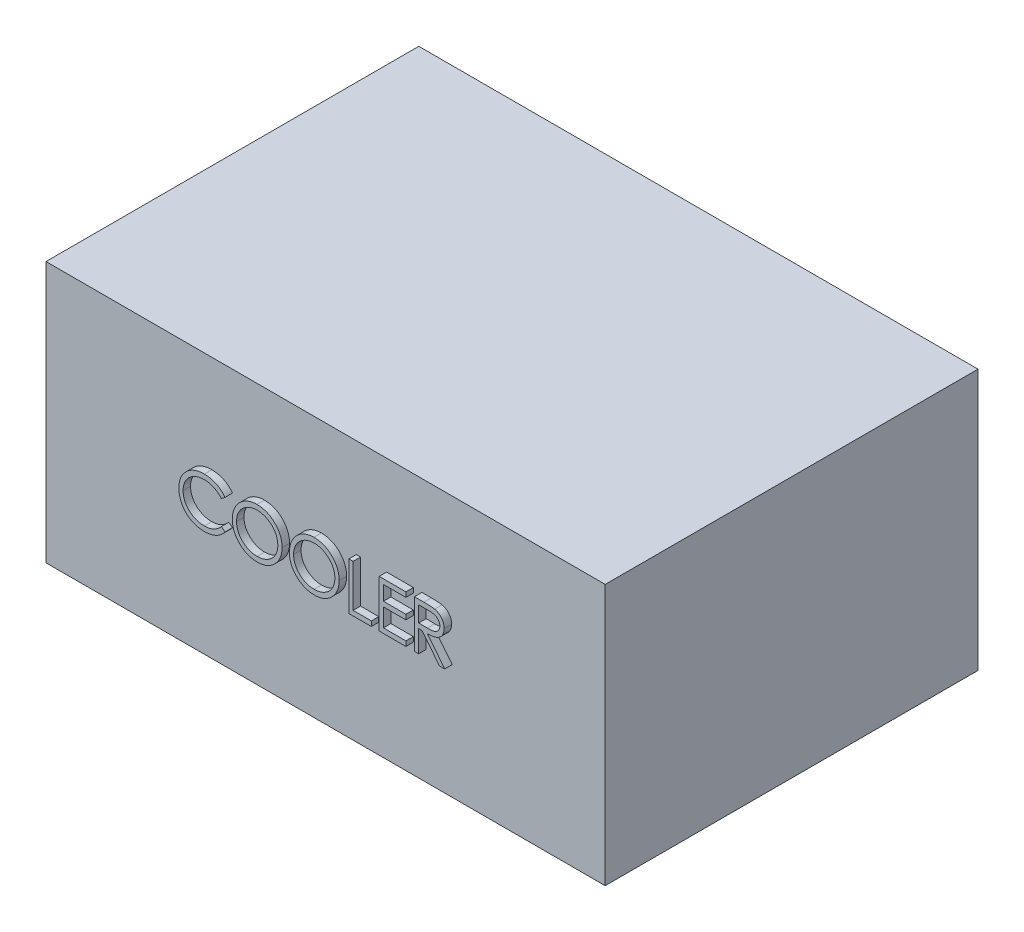
from build123d import *

# Parameters (mm, degrees)
SKETCH_1_W      = 150
SKETCH_1_H      = 70
EXTRUDE_1_DEPTH = 100
EXTRUDE_2_DEPTH = 2


with BuildPart() as part:
    # 스케치1 → 보스-돌출1 (new body)
    with BuildSketch(Plane.XY):
        with Locations((75, -35)):
            Rectangle(SKETCH_1_W, SKETCH_1_H)
    extrude(amount=EXTRUDE_1_DEPTH)

    # 스케치2 → 보스-돌출2 (add)
    with BuildSketch(Plane.XY.offset(100)):
        with BuildLine():
            Line((50.01625777, -28.786189706), (49.018982129, -29.54941086))
            add(Edge.make_bspline(
                [(49.018982129, -29.54941086), (48.947840763, -29.46462577), (48.80651717, -29.296198676), (48.579153778, -29.059690043), (48.342202102, -28.83811038), (48.095752719, -28.630404131), (47.835369629, -28.443834724), (47.567360445, -28.268679579), (47.287241824, -28.111679501), (46.89988553, -27.921313809), (46.393163337, -27.722663475), (45.755279207, -27.556100321), (45.089396078, -27.450069198), (44.635107645, -27.438585345), (44.404038219, -27.432744194)],
                knots=[0, 0, 0, 0, 0.00033196, 0.000659444, 0.000983431, 0.001304932, 0.001625525, 0.001943778, 0.002265016, 0.002588143, 0.003238217, 0.003893566, 0.004562806, 0.005255583, 0.005255583, 0.005255583, 0.005255583], degree=3))
            add(Edge.make_bspline(
                [(44.404038219, -27.432744194), (44.276735961, -27.43421), (44.023312931, -27.43712801), (43.647217041, -27.475623979), (43.27814397, -27.529730369), (42.916333793, -27.610013685), (42.562247057, -27.711514331), (42.213568913, -27.832800833), (41.875347593, -27.982859824), (41.542904272, -28.14871551), (41.224391135, -28.336049381), (40.923019962, -28.5403864), (40.639889906, -28.759439979), (40.374777, -28.994031136), (40.127410216, -29.243103393), (39.899581974, -29.509311147), (39.692080628, -29.791803319), (39.500793137, -30.086854827), (39.329478361, -30.393606242), (39.186041371, -30.713192926), (39.059022784, -31.0401421), (38.958514104, -31.378147741), (38.878959428, -31.724831491), (38.824067622, -32.081123779), (38.786009455, -32.446280273), (38.783105956, -32.693782636), (38.781642385, -32.818541469)],
                knots=[0, 0, 0, 0, 0.000381746, 0.00075995, 0.001133062, 0.001500343, 0.001870765, 0.002237676, 0.002606812, 0.002979993, 0.003351741, 0.00371443, 0.004071661, 0.004424911, 0.004775707, 0.005123948, 0.005475039, 0.005826461, 0.006178335, 0.006527846, 0.006876532, 0.007229865, 0.007584733, 0.007942761, 0.008310834, 0.008684951, 0.008684951, 0.008684951, 0.008684951], degree=3))
            add(Edge.make_bspline(
                [(38.781642385, -32.818541469), (38.786220986, -33.006252259), (38.79521046, -33.374797495), (38.875214416, -33.914622282), (38.996790032, -34.431768727), (39.17900084, -34.923004155), (39.403678538, -35.394385911), (39.687580185, -35.837938322), (40.016388764, -36.260364142), (40.394755943, -36.651679981), (40.809885618, -37.00914407), (41.255285183, -37.323924751), (41.729845313, -37.586324468), (42.228326228, -37.804677188), (42.754563842, -37.972523028), (43.307611839, -38.090684276), (43.886267365, -38.167763046), (44.281670616, -38.175142428), (44.482904405, -38.17889804)],
                knots=[0, 0, 0, 0, 0.000562815, 0.001105012, 0.001633818, 0.00215373, 0.002673724, 0.003197432, 0.003730267, 0.004277248, 0.00482748, 0.005371661, 0.005910344, 0.006451519, 0.007001839, 0.007564217, 0.008146414, 0.008749794, 0.008749794, 0.008749794, 0.008749794], degree=3))
            add(Edge.make_bspline(
                [(44.482904405, -38.17889804), (44.704619876, -38.172770182), (45.141008963, -38.160709092), (45.780972944, -38.058531245), (46.393605579, -37.892858229), (46.978939822, -37.661000053), (47.535325538, -37.359591723), (48.06363342, -36.994202282), (48.564309404, -36.561356046), (48.865376628, -36.230854409), (49.018982129, -36.062231373)],
                knots=[0, 0, 0, 0, 0.000664826, 0.001308536, 0.001938654, 0.00256556, 0.003192755, 0.00383282, 0.004489298, 0.005173128, 0.005173128, 0.005173128, 0.005173128], degree=3))
            Line((49.018982129, -36.062231373), (50.01625777, -36.817820315))
            add(Edge.make_bspline(
                [(50.01625777, -36.817820315), (49.936000628, -36.921374127), (49.775870772, -37.127985732), (49.516580254, -37.419257365), (49.243431203, -37.693229151), (48.95439477, -37.947692233), (48.652795926, -38.187738437), (48.33321925, -38.406547939), (47.999865903, -38.607174862), (47.653865365, -38.790878274), (47.295585256, -38.953863713), (46.925454878, -39.093395956), (46.545069647, -39.213591984), (46.154412173, -39.312477583), (45.752672141, -39.38966123), (45.341299278, -39.441258336), (44.919405731, -39.476607569), (44.634775432, -39.479829435), (44.490536616, -39.481462142)],
                knots=[0, 0, 0, 0, 0.00039295, 0.000784017, 0.001168988, 0.001552873, 0.001938676, 0.002324679, 0.002713864, 0.003105353, 0.00349929, 0.003893826, 0.004291304, 0.004695459, 0.005102104, 0.005517692, 0.005938765, 0.006371376, 0.006371376, 0.006371376, 0.006371376], degree=3))
            add(Edge.make_bspline(
                [(44.490536616, -39.481462142), (44.353943881, -39.480511484), (44.083848663, -39.478631674), (43.685073193, -39.448180095), (43.296853857, -39.406633907), (42.920300214, -39.34407686), (42.553357391, -39.270255969), (42.199351841, -39.171300266), (41.854800078, -39.060450433), (41.521086384, -38.930166624), (41.197926902, -38.783150762), (40.88636393, -38.616992819), (40.586540761, -38.433090053), (40.295509662, -38.235496158), (40.017569859, -38.017864234), (39.750312781, -37.783216732), (39.492239796, -37.532344522), (39.33257291, -37.351442625), (39.25229543, -37.260488585)],
                knots=[0, 0, 0, 0, 0.000409666, 0.000810065, 0.001199174, 0.001580615, 0.001954827, 0.00232143, 0.002682661, 0.003040299, 0.003395496, 0.003747176, 0.004098847, 0.004450261, 0.004801913, 0.005157073, 0.005516877, 0.005880706, 0.005880706, 0.005880706, 0.005880706], degree=3))
            add(Edge.make_bspline(
                [(39.25229543, -37.260488585), (39.123714667, -37.102496271), (38.868105479, -36.788419064), (38.541077999, -36.279381361), (38.261142584, -35.747911003), (38.0348071, -35.191215833), (37.85786804, -34.610545028), (37.735290561, -34.005605875), (37.655637596, -33.376963342), (37.646528834, -32.949384138), (37.641898796, -32.732043072)],
                knots=[0, 0, 0, 0, 0.000610709, 0.001214046, 0.001811469, 0.002410515, 0.003014109, 0.003629806, 0.004260284, 0.004912063, 0.004912063, 0.004912063, 0.004912063], degree=3))
            add(Edge.make_bspline(
                [(37.641898796, -32.732043072), (37.647541926, -32.503604712), (37.658644434, -32.0541665), (37.752972035, -31.394586727), (37.904714524, -30.762665936), (38.120240377, -30.159583777), (38.393491223, -29.582168189), (38.731044936, -29.034830103), (39.128979995, -28.514069144), (39.584175455, -28.027787047), (40.083348357, -27.583144253), (40.617905196, -27.191961742), (41.18679969, -26.866415327), (41.783764466, -26.594286395), (42.413269653, -26.385119343), (43.073972164, -26.238694923), (43.764630512, -26.147555672), (44.235845599, -26.136034203), (44.475272193, -26.130180091)],
                knots=[0, 0, 0, 0, 0.000685036, 0.001347765, 0.001994424, 0.002631723, 0.003265569, 0.003907406, 0.004557186, 0.005228594, 0.005902557, 0.006560016, 0.007211953, 0.007865497, 0.008525192, 0.009197944, 0.009893113, 0.01061119, 0.01061119, 0.01061119, 0.01061119], degree=3))
            add(Edge.make_bspline(
                [(44.475272193, -26.130180091), (44.621193277, -26.131929564), (44.910029367, -26.135392469), (45.337303277, -26.169160471), (45.753291149, -26.225452699), (46.15827957, -26.302073867), (46.554238777, -26.397169005), (46.938142508, -26.521049516), (47.312243458, -26.662696358), (47.674182239, -26.825831363), (48.022222292, -27.008953539), (48.35625522, -27.210033087), (48.673627707, -27.428820724), (48.976572957, -27.663455675), (49.260023208, -27.918901876), (49.532026288, -28.188133153), (49.783345057, -28.478904457), (49.938478079, -28.683573789), (50.01625777, -28.786189706)],
                knots=[0, 0, 0, 0, 0.000437698, 0.00086638, 0.001284824, 0.001696468, 0.002102476, 0.002505573, 0.002905769, 0.003302024, 0.003695764, 0.004084948, 0.004470952, 0.004851611, 0.005233595, 0.005614968, 0.005999089, 0.006385327, 0.006385327, 0.006385327, 0.006385327], degree=3))
        make_face()
        with BuildLine():
            add(Edge.make_bspline(
                [(58.564334693, -26.130180091), (58.799495534, -26.136136316), (59.261370829, -26.147834834), (59.940185458, -26.237384724), (60.588230518, -26.392307996), (61.210785021, -26.59863939), (61.800402393, -26.873882445), (62.361520661, -27.206568555), (62.892804746, -27.600183134), (63.387093759, -28.051683471), (63.839420407, -28.542932004), (64.23793148, -29.06718042), (64.571913517, -29.621258932), (64.846181945, -30.203502517), (65.061351186, -30.812594401), (65.209828858, -31.451781782), (65.304673003, -32.116923201), (65.31576111, -32.57059211), (65.321385975, -32.800732976)],
                knots=[0, 0, 0, 0, 0.000705368, 0.001385402, 0.00204938, 0.002701839, 0.003349503, 0.003997423, 0.004655841, 0.005329419, 0.006002834, 0.006656665, 0.007301525, 0.007939971, 0.008584465, 0.009235478, 0.009905767, 0.010595886, 0.010595886, 0.010595886, 0.010595886], degree=3))
            add(Edge.make_bspline(
                [(65.321385975, -32.800732976), (65.315761934, -33.029178567), (65.304676298, -33.479471292), (65.20972102, -34.14039179), (65.06080082, -34.775720888), (64.848180082, -35.384397971), (64.575219061, -35.967065131), (64.239013154, -36.522189221), (63.842986475, -37.04995223), (63.392293044, -37.544572472), (62.900980692, -37.998134723), (62.374002295, -38.393354643), (61.823209391, -38.733439324), (61.241514164, -39.004797226), (60.636631174, -39.221683909), (60.003146744, -39.369557738), (59.344029248, -39.464942152), (58.894554463, -39.475895053), (58.666097513, -39.481462142)],
                knots=[0, 0, 0, 0, 0.000685036, 0.001350284, 0.001998823, 0.002640075, 0.003280822, 0.003925683, 0.00458358, 0.005257158, 0.005930573, 0.006586435, 0.007230442, 0.007868887, 0.008508583, 0.009154647, 0.009817376, 0.010502411, 0.010502411, 0.010502411, 0.010502411], degree=3))
            add(Edge.make_bspline(
                [(58.666097513, -39.481462142), (58.435957842, -39.475840082), (57.982291287, -39.464757503), (57.316314044, -39.369756406), (56.676677659, -39.22119796), (56.065211299, -39.008892292), (55.481573983, -38.734509769), (54.924624255, -38.399939593), (54.396597635, -38.002947967), (53.901871869, -37.552400682), (53.449210493, -37.06192105), (53.054569329, -36.53637961), (52.719923918, -35.986086953), (52.446462683, -35.409515937), (52.229965931, -34.809453845), (52.08226559, -34.181897941), (51.986703707, -33.53042602), (51.97569155, -33.086858932), (51.970103924, -32.861790668)],
                knots=[0, 0, 0, 0, 0.000690119, 0.001360408, 0.002013897, 0.002657552, 0.003298299, 0.003945339, 0.004603236, 0.005276814, 0.005950229, 0.006602529, 0.007245213, 0.007879059, 0.008513962, 0.009155077, 0.009810248, 0.010485118, 0.010485118, 0.010485118, 0.010485118], degree=3))
            add(Edge.make_bspline(
                [(51.970103924, -32.861790668), (51.972043887, -32.710723554), (51.97589934, -32.410495106), (52.022314909, -31.964664871), (52.089667368, -31.526004485), (52.186194308, -31.095761331), (52.312438357, -30.674988615), (52.46139857, -30.260784418), (52.643334581, -29.857346335), (52.849004361, -29.46276317), (53.07855435, -29.083185912), (53.332103498, -28.724394282), (53.600746121, -28.383377522), (53.895253292, -28.06897268), (54.205918679, -27.772033412), (54.537781936, -27.497122982), (54.88881808, -27.241762445), (55.260537572, -27.011637208), (55.643781027, -26.803505491), (56.038848192, -26.624900489), (56.440373466, -26.471607637), (56.850237474, -26.347362357), (57.267351818, -26.249274683), (57.692626865, -26.182482286), (58.125723812, -26.135948332), (58.417502027, -26.132111111), (58.564334693, -26.130180091)],
                knots=[0, 0, 0, 0, 0.000453023, 0.000900331, 0.00134327, 0.001783953, 0.002221843, 0.002660465, 0.003103469, 0.003548398, 0.003994743, 0.004433047, 0.004865726, 0.005295975, 0.005724256, 0.006154227, 0.006587795, 0.007025471, 0.007464852, 0.007895214, 0.008325184, 0.00875333, 0.009179133, 0.00960951, 0.010044159, 0.010484467, 0.010484467, 0.010484467, 0.010484467], degree=3))
        make_face()
        with BuildLine():
            add(Edge.make_bspline(
                [(58.620304244, -27.432744194), (58.499782574, -27.434213367), (58.259891429, -27.437137668), (57.903258969, -27.47565755), (57.551316809, -27.530557433), (57.203992266, -27.608867523), (56.862738587, -27.715562228), (56.524374878, -27.838356381), (56.191986654, -27.987930053), (55.866671227, -28.156922437), (55.551293669, -28.343971378), (55.253704723, -28.550697504), (54.973133987, -28.77225283), (54.710268419, -29.009154411), (54.46587988, -29.26260868), (54.235158249, -29.528773234), (54.027351481, -29.81525581), (53.836903817, -30.114287858), (53.666477654, -30.425479881), (53.514929081, -30.745555667), (53.390962534, -31.077126131), (53.289861912, -31.416594074), (53.206042598, -31.763421856), (53.152942359, -32.120240508), (53.113999227, -32.485257057), (53.111242073, -32.73193407), (53.109847513, -32.856702527)],
                knots=[0, 0, 0, 0, 0.000361401, 0.000719348, 0.001074863, 0.001429731, 0.001786237, 0.002146831, 0.002508984, 0.002878794, 0.003246164, 0.003608191, 0.003964987, 0.004318036, 0.004668869, 0.005020697, 0.005373837, 0.005729543, 0.006083645, 0.0064376, 0.006791042, 0.007144375, 0.007499817, 0.007860358, 0.0082259, 0.008600016, 0.008600016, 0.008600016, 0.008600016], degree=3))
            add(Edge.make_bspline(
                [(53.109847513, -32.856702527), (53.114473441, -33.040171157), (53.123574072, -33.401110709), (53.203248684, -33.930040832), (53.325974134, -34.438361185), (53.506885149, -34.923290399), (53.733128808, -35.388996796), (54.012626381, -35.831349062), (54.343766492, -36.250466749), (54.719917003, -36.643423868), (55.131116538, -37.002092929), (55.567752444, -37.316920154), (56.025146962, -37.583294489), (56.504492869, -37.800301466), (57.003231082, -37.972258515), (57.524575339, -38.090109548), (58.065052721, -38.167671915), (58.433463955, -38.175120486), (58.620304244, -38.17889804)],
                knots=[0, 0, 0, 0, 0.000550108, 0.001082232, 0.001601154, 0.002116289, 0.002631707, 0.003151905, 0.003682739, 0.004231557, 0.004781529, 0.005317417, 0.005844089, 0.006366671, 0.006893638, 0.007423745, 0.007968111, 0.008528275, 0.008528275, 0.008528275, 0.008528275], degree=3))
            add(Edge.make_bspline(
                [(58.620304244, -38.17889804), (58.745887293, -38.177172638), (58.994956196, -38.173750649), (59.365417092, -38.139284021), (59.729203917, -38.084014095), (60.085806418, -38.004437145), (60.434819877, -37.904842996), (60.77770102, -37.786523526), (61.110797673, -37.638908872), (61.438311942, -37.47581202), (61.751806876, -37.289883448), (62.051075236, -37.090173591), (62.328573791, -36.868944595), (62.591242708, -36.635562819), (62.836634608, -36.385322571), (63.063090065, -36.118549194), (63.269846544, -35.833558809), (63.460221891, -35.534980337), (63.630050873, -35.222936792), (63.778020746, -34.901700532), (63.903555224, -34.572062563), (64.004895798, -34.233547433), (64.084308759, -33.886798067), (64.139027326, -33.531350183), (64.177303089, -33.167914855), (64.180188083, -32.922101435), (64.181642385, -32.798188905)],
                knots=[0, 0, 0, 0, 0.00037666, 0.00074703, 0.001115112, 0.001479909, 0.001842294, 0.002203561, 0.002567016, 0.002934509, 0.003300581, 0.003659737, 0.00401296, 0.004364308, 0.004713319, 0.005063497, 0.005413082, 0.005768788, 0.006125121, 0.006478005, 0.006829068, 0.007182401, 0.00753727, 0.007895297, 0.008260839, 0.008632412, 0.008632412, 0.008632412, 0.008632412], degree=3))
            add(Edge.make_bspline(
                [(64.181642385, -32.798188905), (64.180186918, -32.675124075), (64.177299731, -32.431002316), (64.139045609, -32.070101632), (64.08425095, -31.717211408), (64.005283409, -31.373717037), (63.903501423, -31.03953096), (63.777998824, -30.714967047), (63.630006451, -30.398816168), (63.460159466, -30.091859719), (63.269239192, -29.797311384), (63.060617223, -29.515725487), (62.830691532, -29.252390111), (62.586031384, -29.000804222), (62.3205256, -28.766333594), (62.035376876, -28.548900447), (61.73404696, -28.343257423), (61.414996705, -28.15774467), (61.085725787, -27.986424455), (60.74785514, -27.8396451), (60.405212407, -27.71492341), (60.058668914, -27.608544708), (59.705307821, -27.530864142), (59.347516785, -27.475608075), (58.985790818, -27.437151075), (58.742519706, -27.434217816), (58.620304244, -27.432744194)],
                knots=[0, 0, 0, 0, 0.000369031, 0.00073204, 0.001087555, 0.001439943, 0.001788407, 0.002134718, 0.002482986, 0.00283486, 0.003186283, 0.003535331, 0.003885231, 0.004234241, 0.004587492, 0.004946738, 0.005309426, 0.005681174, 0.006053244, 0.006422379, 0.006785362, 0.007146737, 0.00750905, 0.007869591, 0.0082326, 0.008599088, 0.008599088, 0.008599088, 0.008599088], degree=3))
        make_face(mode=Mode.SUBTRACT)
        with BuildLine():
            add(Edge.make_bspline(
                [(73.869462898, -26.130180091), (74.10462374, -26.136136316), (74.566499034, -26.147834834), (75.245313663, -26.237384724), (75.893358723, -26.392307996), (76.515913226, -26.59863939), (77.105530599, -26.873882445), (77.666648866, -27.206568555), (78.197932951, -27.600183134), (78.692221964, -28.051683471), (79.144548612, -28.542932004), (79.543059685, -29.06718042), (79.877041722, -29.621258932), (80.15131015, -30.203502517), (80.366479391, -30.812594401), (80.514957064, -31.451781782), (80.609801208, -32.116923201), (80.620889315, -32.57059211), (80.62651418, -32.800732976)],
                knots=[0, 0, 0, 0, 0.000705368, 0.001385402, 0.00204938, 0.002701839, 0.003349503, 0.003997423, 0.004655841, 0.005329419, 0.006002834, 0.006656665, 0.007301525, 0.007939971, 0.008584465, 0.009235478, 0.009905767, 0.010595886, 0.010595886, 0.010595886, 0.010595886], degree=3))
            add(Edge.make_bspline(
                [(80.62651418, -32.800732976), (80.620890139, -33.029178567), (80.609804503, -33.479471292), (80.514849225, -34.14039179), (80.365929025, -34.775720888), (80.153308287, -35.384397971), (79.880347266, -35.967065131), (79.544141359, -36.522189221), (79.14811468, -37.04995223), (78.697421249, -37.544572472), (78.206108897, -37.998134723), (77.6791305, -38.393354643), (77.128337596, -38.733439324), (76.546642369, -39.004797226), (75.941759379, -39.221683909), (75.308274949, -39.369557738), (74.649157453, -39.464942152), (74.199682668, -39.475895053), (73.971225719, -39.481462142)],
                knots=[0, 0, 0, 0, 0.000685036, 0.001350284, 0.001998823, 0.002640075, 0.003280822, 0.003925683, 0.00458358, 0.005257158, 0.005930573, 0.006586435, 0.007230442, 0.007868887, 0.008508583, 0.009154647, 0.009817376, 0.010502411, 0.010502411, 0.010502411, 0.010502411], degree=3))
            add(Edge.make_bspline(
                [(73.971225719, -39.481462142), (73.741086047, -39.475840082), (73.287419492, -39.464757503), (72.621442249, -39.369756406), (71.981805864, -39.22119796), (71.370339504, -39.008892292), (70.786702188, -38.734509769), (70.22975246, -38.399939593), (69.70172584, -38.002947967), (69.207000074, -37.552400682), (68.754338698, -37.06192105), (68.359697534, -36.53637961), (68.025052123, -35.986086953), (67.751590888, -35.409515937), (67.535094136, -34.809453845), (67.387393796, -34.181897941), (67.291831912, -33.53042602), (67.280819755, -33.086858932), (67.275232129, -32.861790668)],
                knots=[0, 0, 0, 0, 0.000690119, 0.001360408, 0.002013897, 0.002657552, 0.003298299, 0.003945339, 0.004603236, 0.005276814, 0.005950229, 0.006602529, 0.007245213, 0.007879059, 0.008513962, 0.009155077, 0.009810248, 0.010485118, 0.010485118, 0.010485118, 0.010485118], degree=3))
            add(Edge.make_bspline(
                [(67.275232129, -32.861790668), (67.277172092, -32.710723554), (67.281027545, -32.410495106), (67.327443115, -31.964664871), (67.394795573, -31.526004485), (67.491322513, -31.095761331), (67.617566562, -30.674988615), (67.766526775, -30.260784418), (67.948462786, -29.857346335), (68.154132566, -29.46276317), (68.383682555, -29.083185912), (68.637231703, -28.724394282), (68.905874326, -28.383377522), (69.200381497, -28.06897268), (69.511046884, -27.772033412), (69.842910141, -27.497122982), (70.193946285, -27.241762445), (70.565665778, -27.011637208), (70.948909232, -26.803505491), (71.343976397, -26.624900489), (71.745501671, -26.471607637), (72.155365679, -26.347362357), (72.572480024, -26.249274683), (72.99775507, -26.182482286), (73.430852017, -26.135948332), (73.722630232, -26.132111111), (73.869462898, -26.130180091)],
                knots=[0, 0, 0, 0, 0.000453023, 0.000900331, 0.00134327, 0.001783953, 0.002221843, 0.002660465, 0.003103469, 0.003548398, 0.003994743, 0.004433047, 0.004865726, 0.005295975, 0.005724256, 0.006154227, 0.006587795, 0.007025471, 0.007464852, 0.007895214, 0.008325184, 0.00875333, 0.009179133, 0.00960951, 0.010044159, 0.010484467, 0.010484467, 0.010484467, 0.010484467], degree=3))
        make_face()
        with BuildLine():
            add(Edge.make_bspline(
                [(73.925432449, -27.432744194), (73.804910779, -27.434213367), (73.565019634, -27.437137668), (73.208387174, -27.47565755), (72.856445014, -27.530557433), (72.509120471, -27.608867523), (72.167866793, -27.715562228), (71.829503083, -27.838356381), (71.497114859, -27.987930053), (71.171799432, -28.156922437), (70.856421874, -28.343971378), (70.558832928, -28.550697504), (70.278262192, -28.77225283), (70.015396624, -29.009154411), (69.771008085, -29.26260868), (69.540286454, -29.528773234), (69.332479686, -29.81525581), (69.142032022, -30.114287858), (68.971605859, -30.425479881), (68.820057286, -30.745555667), (68.69609074, -31.077126131), (68.594990117, -31.416594074), (68.511170803, -31.763421856), (68.458070565, -32.120240508), (68.419127432, -32.485257057), (68.416370278, -32.73193407), (68.414975719, -32.856702527)],
                knots=[0, 0, 0, 0, 0.000361401, 0.000719348, 0.001074863, 0.001429731, 0.001786237, 0.002146831, 0.002508984, 0.002878794, 0.003246164, 0.003608191, 0.003964987, 0.004318036, 0.004668869, 0.005020697, 0.005373837, 0.005729543, 0.006083645, 0.0064376, 0.006791042, 0.007144375, 0.007499817, 0.007860358, 0.0082259, 0.008600016, 0.008600016, 0.008600016, 0.008600016], degree=3))
            add(Edge.make_bspline(
                [(68.414975719, -32.856702527), (68.419601646, -33.040171157), (68.428702277, -33.401110709), (68.508376889, -33.930040832), (68.631102339, -34.438361185), (68.812013354, -34.923290399), (69.038257013, -35.388996796), (69.317754586, -35.831349062), (69.648894697, -36.250466749), (70.025045208, -36.643423868), (70.436244743, -37.002092929), (70.872880649, -37.316920154), (71.330275167, -37.583294489), (71.809621074, -37.800301466), (72.308359287, -37.972258515), (72.829703544, -38.090109548), (73.370180926, -38.167671915), (73.73859216, -38.175120486), (73.925432449, -38.17889804)],
                knots=[0, 0, 0, 0, 0.000550108, 0.001082232, 0.001601154, 0.002116289, 0.002631707, 0.003151905, 0.003682739, 0.004231557, 0.004781529, 0.005317417, 0.005844089, 0.006366671, 0.006893638, 0.007423745, 0.007968111, 0.008528275, 0.008528275, 0.008528275, 0.008528275], degree=3))
            add(Edge.make_bspline(
                [(73.925432449, -38.17889804), (74.051015498, -38.177172638), (74.300084402, -38.173750649), (74.670545297, -38.139284021), (75.034332122, -38.084014095), (75.390934624, -38.004437145), (75.739948082, -37.904842996), (76.082829225, -37.786523526), (76.415925878, -37.638908872), (76.743440147, -37.47581202), (77.056935081, -37.289883448), (77.356203441, -37.090173591), (77.633701996, -36.868944595), (77.896370913, -36.635562819), (78.141762813, -36.385322571), (78.36821827, -36.118549194), (78.574974749, -35.833558809), (78.765350096, -35.534980337), (78.935179078, -35.222936792), (79.083148951, -34.901700532), (79.208683429, -34.572062563), (79.310024003, -34.233547433), (79.389436964, -33.886798067), (79.444155531, -33.531350183), (79.482431294, -33.167914855), (79.485316288, -32.922101435), (79.48677059, -32.798188905)],
                knots=[0, 0, 0, 0, 0.00037666, 0.00074703, 0.001115112, 0.001479909, 0.001842294, 0.002203561, 0.002567016, 0.002934509, 0.003300581, 0.003659737, 0.00401296, 0.004364308, 0.004713319, 0.005063497, 0.005413082, 0.005768788, 0.006125121, 0.006478005, 0.006829068, 0.007182401, 0.00753727, 0.007895297, 0.008260839, 0.008632412, 0.008632412, 0.008632412, 0.008632412], degree=3))
            add(Edge.make_bspline(
                [(79.48677059, -32.798188905), (79.485315123, -32.675124075), (79.482427936, -32.431002316), (79.444173814, -32.070101632), (79.389379155, -31.717211408), (79.310411614, -31.373717037), (79.208629628, -31.03953096), (79.083127029, -30.714967047), (78.935134656, -30.398816168), (78.765287671, -30.091859719), (78.574367397, -29.797311384), (78.365745429, -29.515725487), (78.135819737, -29.252390111), (77.891159589, -29.000804222), (77.625653805, -28.766333594), (77.340505081, -28.548900447), (77.039175165, -28.343257423), (76.72012491, -28.15774467), (76.390853993, -27.986424455), (76.052983345, -27.8396451), (75.710340612, -27.71492341), (75.363797119, -27.608544708), (75.010436026, -27.530864142), (74.65264499, -27.475608075), (74.290919023, -27.437151075), (74.047647912, -27.434217816), (73.925432449, -27.432744194)],
                knots=[0, 0, 0, 0, 0.000369031, 0.00073204, 0.001087555, 0.001439943, 0.001788407, 0.002134718, 0.002482986, 0.00283486, 0.003186283, 0.003535331, 0.003885231, 0.004234241, 0.004587492, 0.004946738, 0.005309426, 0.005681174, 0.006053244, 0.006422379, 0.006785362, 0.007146737, 0.00750905, 0.007869591, 0.0082326, 0.008599088, 0.008599088, 0.008599088, 0.008599088], degree=3))
        make_face(mode=Mode.SUBTRACT)
        Polygon((83.231642385, -26.455821117), (84.371385975, -26.455821117), (84.371385975, -37.853257014), (89.25600136, -37.853257014), (89.25600136, -39.155821117), (83.231642385, -39.155821117), align=None)
        Polygon((91.372668026, -26.455821117), (98.53677059, -26.455821117), (98.53677059, -27.758385219), (92.512411616, -27.758385219), (92.512411616, -31.666077527), (98.53677059, -31.666077527), (98.53677059, -32.96864163), (92.512411616, -32.96864163), (92.512411616, -37.853257014), (98.53677059, -37.853257014), (98.53677059, -39.155821117), (91.372668026, -39.155821117), align=None)
        with BuildLine():
            Line((100.81625777, -26.455821117), (103.357784212, -26.455821117))
            add(Edge.make_bspline(
                [(103.357784212, -26.455821117), (103.527387736, -26.456385672), (103.853045288, -26.457469679), (104.319582584, -26.463514019), (104.74349805, -26.48083811), (105.124570038, -26.495746399), (105.462791558, -26.522931443), (105.759199727, -26.548914362), (106.012429372, -26.58292736), (106.165721461, -26.614515609), (106.235127962, -26.628817912)],
                knots=[0, 0, 0, 0, 0.00050882, 0.000976992, 0.001399583, 0.001781609, 0.002120925, 0.002417362, 0.00267425, 0.002886798, 0.002886798, 0.002886798, 0.002886798], degree=3))
            add(Edge.make_bspline(
                [(106.235127962, -26.628817912), (106.328043427, -26.651775032), (106.511892217, -26.697199534), (106.776596743, -26.793210086), (107.028834432, -26.904315581), (107.267557509, -27.034812509), (107.491570237, -27.185669566), (107.703182394, -27.354282468), (107.903354218, -27.539728614), (108.083990419, -27.746683611), (108.254312121, -27.96380466), (108.39796228, -28.198586864), (108.521792649, -28.444101549), (108.620382811, -28.702845608), (108.6997686, -28.972309751), (108.755743812, -29.254934814), (108.789312407, -29.549433209), (108.792729997, -29.750303335), (108.794462898, -29.852155251)],
                knots=[0, 0, 0, 0, 0.00028695, 0.000567779, 0.000843397, 0.001113237, 0.001382776, 0.001652556, 0.001924343, 0.002200055, 0.002475849, 0.002751185, 0.003024244, 0.003299685, 0.003580653, 0.003866043, 0.004163002, 0.00446846, 0.00446846, 0.00446846, 0.00446846], degree=3))
            add(Edge.make_bspline(
                [(108.794462898, -29.852155251), (108.789132534, -30.02137406), (108.778731612, -30.351563783), (108.681757664, -30.830756124), (108.522911435, -31.277757352), (108.304024072, -31.692004638), (108.025279118, -32.065423265), (107.690272018, -32.393411489), (107.298815885, -32.667876314), (106.934400939, -32.858205063), (106.612495129, -32.980099331), (106.347488536, -33.065865548), (106.058411218, -33.132130393), (105.74803289, -33.1914943), (105.415061911, -33.236313305), (105.06029634, -33.269139519), (104.683483161, -33.289655639), (104.424624252, -33.292710914), (104.29145809, -33.294282655)],
                knots=[0, 0, 0, 0, 0.00050719, 0.000989658, 0.001459589, 0.001926202, 0.002389733, 0.002852089, 0.003326461, 0.003819151, 0.004080894, 0.004358478, 0.00465405, 0.004969894, 0.005306299, 0.005661468, 0.00603854, 0.006438032, 0.006438032, 0.006438032, 0.006438032], degree=3))
            Line((104.29145809, -33.294282655), (108.957283411, -39.155821117))
            Line((108.957283411, -39.155821117), (107.547868347, -39.155821117))
            Line((107.547868347, -39.155821117), (102.882043026, -33.294282655))
            Line((102.882043026, -33.294282655), (101.95600136, -33.294282655))
            Line((101.95600136, -33.294282655), (101.95600136, -39.155821117))
            Line((101.95600136, -39.155821117), (100.81625777, -39.155821117))
            Line((100.81625777, -39.155821117), (100.81625777, -26.455821117))
        make_face()
        with BuildLine():
            Line((101.95600136, -27.758385219), (101.95600136, -31.991718553))
            Line((101.95600136, -31.991718553), (104.281281808, -32.009527046))
            add(Edge.make_bspline(
                [(104.281281808, -32.009527046), (104.389848807, -32.009575076), (104.600282571, -32.009668172), (104.904722126, -31.99517647), (105.188186532, -31.978690715), (105.449591547, -31.953474519), (105.689053948, -31.920976773), (105.906454048, -31.880325944), (106.102146722, -31.832965603), (106.330378561, -31.75966256), (106.585236832, -31.643526437), (106.862210987, -31.474560199), (107.098076612, -31.262037966), (107.297349998, -31.019019997), (107.457476793, -30.751825609), (107.570369104, -30.46365764), (107.642005966, -30.161790985), (107.650455259, -29.954316136), (107.654719308, -29.849611181)],
                knots=[0, 0, 0, 0, 0.000325651, 0.000631204, 0.000914157, 0.001177428, 0.001418847, 0.001638891, 0.00184066, 0.002022485, 0.00235726, 0.002678438, 0.002991969, 0.003304683, 0.003618388, 0.003922157, 0.004230116, 0.004543873, 0.004543873, 0.004543873, 0.004543873], degree=3))
            add(Edge.make_bspline(
                [(107.654719308, -29.849611181), (107.650357326, -29.747479328), (107.641713469, -29.545091262), (107.571142223, -29.248796958), (107.451800754, -28.969154025), (107.290974348, -28.707300037), (107.095034557, -28.469607795), (106.865281351, -28.266236697), (106.607996785, -28.098417211), (106.367527008, -27.99117703), (106.152591437, -27.925427848), (105.965975242, -27.87915934), (105.755113595, -27.841986552), (105.518982645, -27.812203017), (105.258590442, -27.786603648), (104.972620365, -27.76936148), (104.662969762, -27.759151173), (104.448350898, -27.758646479), (104.33725136, -27.758385219)],
                knots=[0, 0, 0, 0, 0.000306146, 0.000606669, 0.000907656, 0.001214825, 0.001525577, 0.001828332, 0.00213176, 0.0024438, 0.002614386, 0.002805665, 0.003020244, 0.003256281, 0.003519552, 0.003805044, 0.004115587, 0.00444887, 0.00444887, 0.00444887, 0.00444887], degree=3))
            Line((104.33725136, -27.758385219), (101.95600136, -27.758385219))
        make_face(mode=Mode.SUBTRACT)
    extrude(amount=EXTRUDE_2_DEPTH)


solid = part.part
